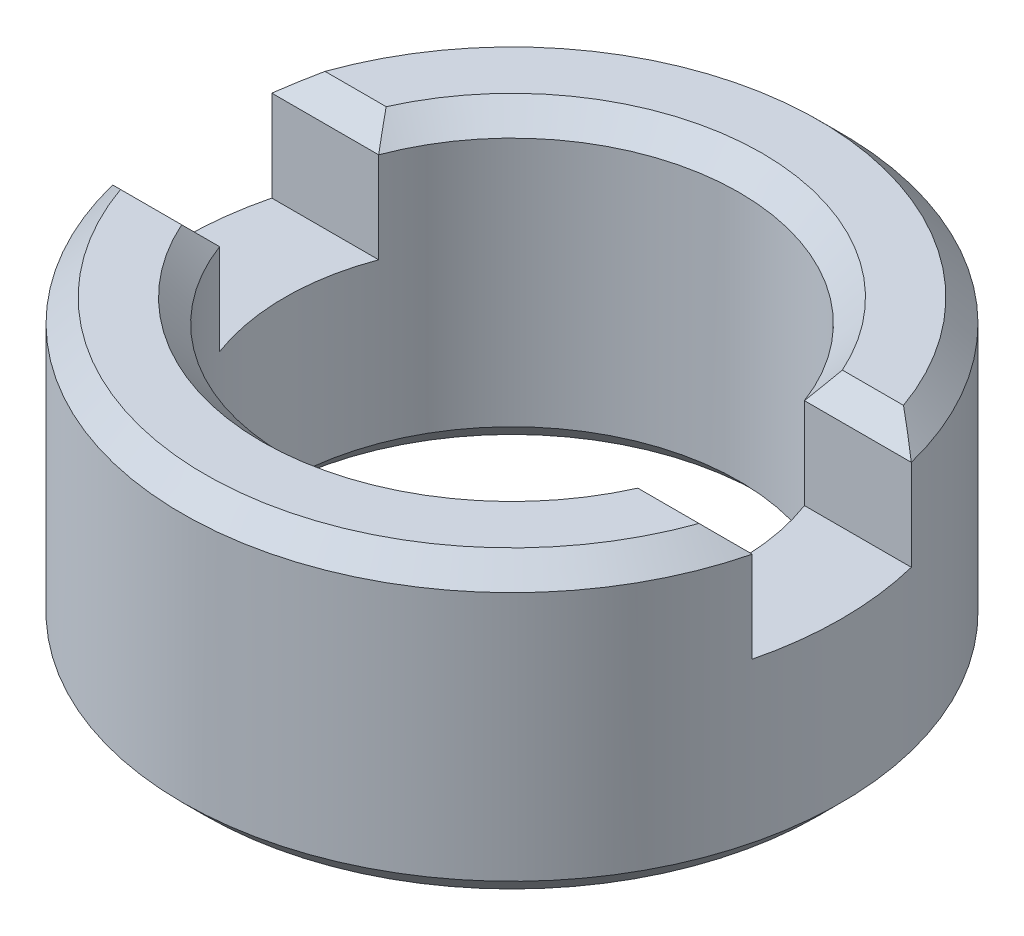
from build123d import *

# Parameters (mm, degrees)
SKETCH1_R           = 1.8415
BOSS_EXTRUDE1_DEPTH = 0.8255
SKETCH3_R           = 1.27
CUT_EXTRUDE2_DEPTH  = 2.651
CUT_EXTRUDE6_DEPTH  = 0.635
CHAMFER1_SIZE       = 0.127


with BuildPart() as part:
    # Sketch1 → Boss-Extrude1 (new body, symmetric)
    with BuildSketch(Plane(origin=(0, 0, 0), x_dir=(1, 0, 0), z_dir=(0, 1, 0))):
        with Locations(Location((0, 0, 0), (0, 0, 270))):  # turned: the seam where the file's is
            Circle(SKETCH1_R)
    extrude(amount=BOSS_EXTRUDE1_DEPTH, both=True)

    # Sketch3 → Cut-Extrude2 (cut, through all)
    with BuildSketch(Plane.XZ.offset(0.8255)):
        with Locations(Location((0, 0, 0), (0, 0, 270))):  # turned: the seam where the file's is
            Circle(SKETCH3_R)
    extrude(amount=-CUT_EXTRUDE2_DEPTH, mode=Mode.SUBTRACT)

    # Sketch7 → Cut-Extrude6 (cut)
    with BuildSketch(Plane.XZ.offset(-0.8255)):
        with BuildLine():
            Line((1.189672119, -0.4445), (1.787048404, -0.4445))
            ThreePointArc((1.787048404, -0.4445), (1.8415, 0), (1.787048404, 0.4445))
            Line((1.787048404, 0.4445), (1.189672119, 0.4445))
            ThreePointArc((1.189672119, 0.4445), (1.27, 0), (1.189672119, -0.4445))
        make_face()
        with BuildLine():
            Line((-1.787048404, 0.4445), (-1.189672119, 0.4445))
            ThreePointArc((-1.189672119, 0.4445), (-1.27, 0), (-1.189672119, -0.4445))
            Line((-1.189672119, -0.4445), (-1.787048404, -0.4445))
            ThreePointArc((-1.787048404, -0.4445), (-1.8415, 0), (-1.787048404, 0.4445))
        make_face()
    extrude(amount=CUT_EXTRUDE6_DEPTH, mode=Mode.SUBTRACT)

    # Chamfer1
    chamfer1_edges = [part.edges().sort_by_distance(p)[0] for p in [
        (0, 0.8255, 1.27),
        (0, 0.8255, -1.8415),
        (1.488360262, 0.8255, 0.4445),
        (1.488360262, 0.8255, -0.4445),
        (0, -0.8255, -1.8415),
        (0.724011395, 0.8255, -1.043411472),
        (1.134146265, 0.8255, 1.450804777),
        (-1.488360262, 0.8255, 0.4445),
        (-1.488360262, 0.8255, -0.4445),
        (0, -0.8255, 1.27),
    ]]
    chamfer(chamfer1_edges, length=CHAMFER1_SIZE)


solid = part.part
